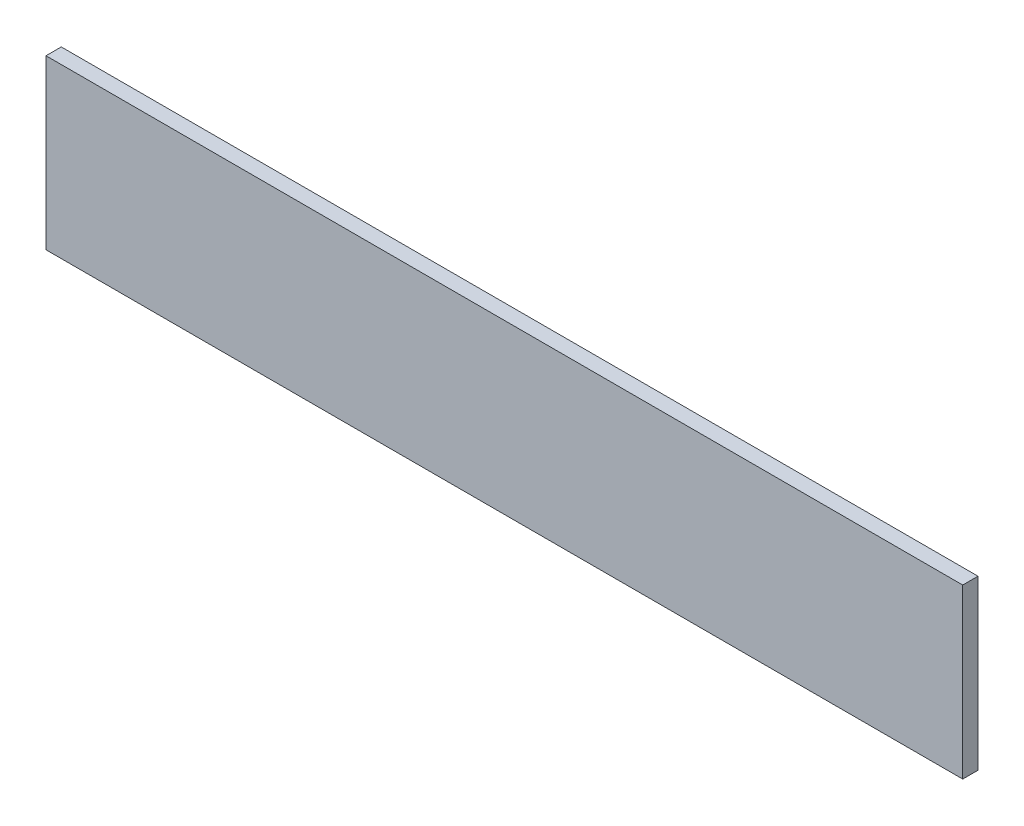
from build123d import *

# Parameters (mm, degrees)
ESQUISSE1_W        = 600
ESQUISSE1_H        = 110
BOSS_EXTRU_1_DEPTH = 10


with BuildPart() as part:
    # Esquisse1 → Boss.-Extru.1 (new body)
    with BuildSketch(Plane.XY):
        with Locations((-300, -55)):
            Rectangle(ESQUISSE1_W, ESQUISSE1_H)
    extrude(amount=BOSS_EXTRU_1_DEPTH)


solid = part.part
